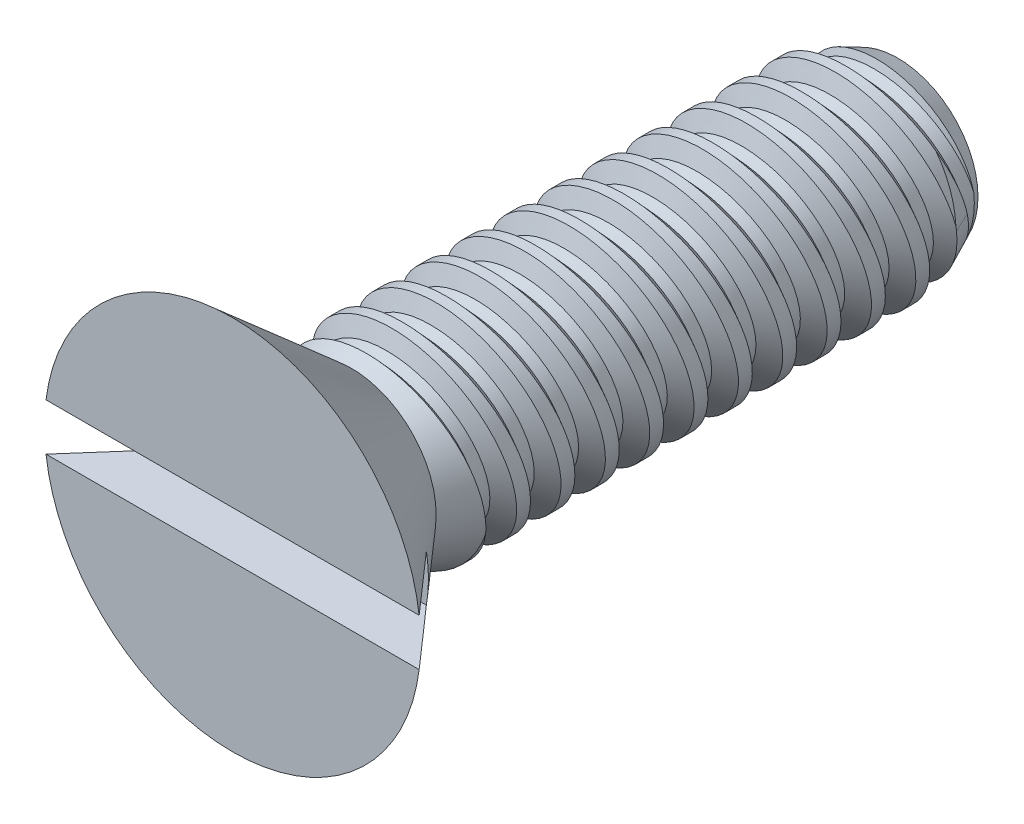
from build123d import *

# Parameters (mm, degrees)
SKETCH1_R          = 2.6924
EXTRUDE3_DEPTH     = 1.7018
SKETCH4_W          = 7.8232
SKETCH4_H          = 1.4224
LPATTERN2_COUNT    = 12
LPATTERN2_PITCH    = 0.635
SKETCH15_W         = 5.3848
SKETCH15_H         = 0.6731
CUT_EXTRUDE5_DEPTH = 0.8509


with BuildPart() as part:
    # Sketch1 → Extrude3 (new body)
    with BuildSketch(Plane.XY):
        Circle(SKETCH1_R)
    extrude(amount=EXTRUDE3_DEPTH)

    # Sketch11 → Cut-Revolve3 (revolve, cut)
    with BuildSketch(Plane(origin=(0, 0, 0), x_dir=(0, 0, -1), z_dir=(1, 0, 0)), mode=Mode.PRIVATE) as cut_revolve3_sk:
        Polygon((0, 1.21304783), (-1.7018, 2.6924), (0, 2.6924), align=None)
    revolve(cut_revolve3_sk.sketch.rotate(Axis((0, 0, -0.441444004), (0, 0, 1)), 90), axis=Axis((0, 0, -0.441444004), (0, 0, 1)), mode=Mode.SUBTRACT)  # turned: the seam where the file's is

    # Sketch4 → Revolve1 (revolve)
    with BuildSketch(Plane(origin=(0, 0, 0), x_dir=(0, 0, -1), z_dir=(1, 0, 0)), mode=Mode.PRIVATE) as revolve1_sk:
        with Locations((3.9116, 0.7112)):
            Rectangle(SKETCH4_W, SKETCH4_H)
    revolve(revolve1_sk.sketch.rotate(Axis((0, 0, -7.8232), (0, 0, -1)), 270), axis=Axis((0, 0, -7.8232), (0, 0, -1)))  # turned: the seam where the file's is

    # Sketch5 → Cut-Revolve1 (revolve, cut)
    with BuildSketch(Plane(origin=(0, 0, 0), x_dir=(0, 0, -1), z_dir=(1, 0, 0)), mode=Mode.PRIVATE) as cut_revolve1_sk:
        Polygon((0.077468538, 1.439692084), (0.346016806, 1.147473684), (0.500953883, 1.182057853), (0.619748307, 1.560736676), align=None)
    cut_revolve1 = revolve(cut_revolve1_sk.sketch.rotate(Axis((0, -0.152561988, 0), (0, 0.217853033, -0.975981586)), 180), axis=Axis((0, -0.152561988, 0), (0, 0.217853033, -0.975981586)), mode=Mode.SUBTRACT)  # turned: the seam where the file's is

    # Sketch13 → Cut-Revolve4 (revolve, cut)
    with BuildSketch(Plane(origin=(0, 0, 0), x_dir=(0, 0, -1), z_dir=(1, 0, 0)), mode=Mode.PRIVATE) as cut_revolve4_sk:
        Polygon((7.8232, 1.147473684), (7.233618614, 1.4224), (7.8232, 1.4224), align=None)
    revolve(cut_revolve4_sk.sketch.rotate(Axis((0, 0, 0), (0, 0, -1)), 90), axis=Axis((0, 0, 0), (0, 0, -1)), mode=Mode.SUBTRACT)  # turned: the seam where the file's is

    # Sketch16 → Cut-Revolve5 (revolve, cut)
    with BuildSketch(Plane(origin=(0, 0, 0), x_dir=(0, 0, -1), z_dir=(1, 0, 0)), mode=Mode.PRIVATE) as cut_revolve5_sk:
        Polygon((0, 1.21304783), (0.575190361, 1.4224), (0, 1.4224), align=None)
    revolve(cut_revolve5_sk.sketch.rotate(Axis((0, 0, 0), (0, 0, -1)), 90), axis=Axis((0, 0, 0), (0, 0, -1)), mode=Mode.SUBTRACT)  # turned: the seam where the file's is

    # LPattern2: Cut-Revolve1 ×12
    with Locations(*[(0, 0, -i * LPATTERN2_PITCH) for i in range(1, LPATTERN2_COUNT)]):
        add(cut_revolve1, mode=Mode.SUBTRACT)

    # Sketch15 → Cut-Extrude5 (cut)
    with BuildSketch(Plane.XY.offset(1.7018)):
        Rectangle(SKETCH15_W, SKETCH15_H)
    extrude(amount=-CUT_EXTRUDE5_DEPTH, mode=Mode.SUBTRACT)


solid = part.part
